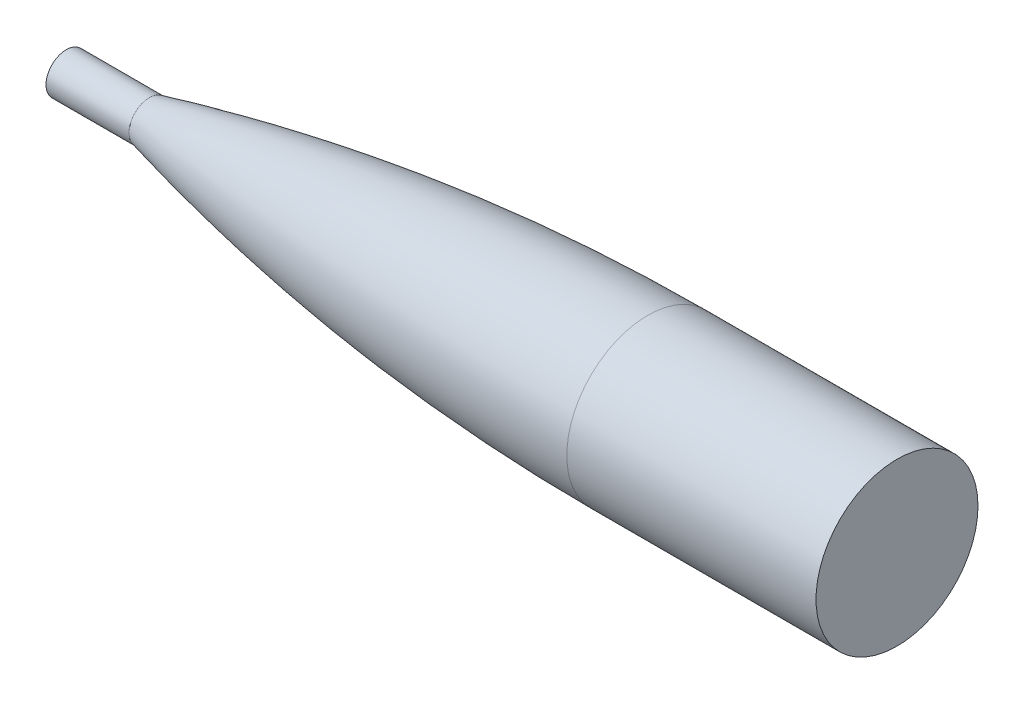
from build123d import *

# Parameters (mm, degrees)
SKETCH2_R           = 49.53
BOSS_EXTRUDE1_DEPTH = 152.4
SKETCH3_R           = 12.411567775
BOSS_EXTRUDE2_DEPTH = 50.8


with BuildPart() as part:
    # Sketch1 → Revolve2 (revolve)
    with BuildSketch(Plane(origin=(0, 0, 0), x_dir=(1, 0, 0), z_dir=(0, 1, 0))):
        with BuildLine():
            Line((355.600000053, 50.799999973), (355.600000053, 1.269999973))
            Line((355.600000053, 1.269999973), (50.800000047, 1.269999973))
            Line((50.800000047, 1.269999973), (50.800000047, 13.68156774))
            add(Edge.make_bspline(
                [(50.800000047, 13.68156774), (51.224607869, 13.786541703), (52.079748124, 13.99736018), (53.901316113, 14.445024847), (55.90428978, 14.933081433), (57.918204029, 15.420277853), (59.969167456, 15.913068852), (62.005618607, 16.398707152), (64.04585603, 16.881716673), (66.619566178, 17.486536085), (69.727395203, 18.209576077), (73.370678613, 19.04644661), (77.55044141, 19.991710093), (82.779136229, 21.155661521), (97.433989811, 24.348822924), (119.485629173, 28.81699746), (168.00075752, 37.516041455), (219.035004801, 44.081341124), (262.822405655, 47.820230422), (299.206459448, 49.570692635), (308.841173655, 49.947366018), (315.265578413, 50.162354186), (319.548981494, 50.29122703), (323.832782669, 50.405645805), (328.116966628, 50.505609209), (332.401425999, 50.591116104), (336.139078075, 50.653092889), (339.329601827, 50.697064227), (341.973247658, 50.727612371), (344.069774299, 50.748376802), (346.163273231, 50.76568058), (348.272494467, 50.77952366), (350.344714481, 50.789906003), (352.405704949, 50.79682758), (354.282013928, 50.799423175), (355.162608625, 50.799999974), (355.600000053, 50.799999973)],
                knots=[0.08282658, 0.08282658, 0.08282658, 0.08282658, 0.08282658, 0.088510594, 0.094194608, 0.099878623, 0.105562637, 0.111246651, 0.116930666, 0.12261468, 0.128298694, 0.139917182, 0.15153567, 0.163154157, 0.174772645, 0.198009616, 0.314194483, 0.407142375, 0.709223026, 0.755696971, 0.790552431, 0.802170918, 0.813789405, 0.825407891, 0.837026378, 0.848644864, 0.860263351, 0.871881838, 0.877565852, 0.883249866, 0.88893388, 0.894617894, 0.900301908, 0.905985922, 0.911669936, 0.91735395, 0.91735395, 0.91735395, 0.91735395, 0.91735395], degree=4))
        make_face()
    revolve(axis=Axis((355.600000053, 0, -1.269999973), (-1, 0, 0)))

    # Sketch2 → Boss-Extrude1 (add)
    with BuildSketch(Plane(origin=(355.600000053, 0, 0), x_dir=(0, 0, -1), z_dir=(1, 0, 0))):
        with Locations((1.269999973, 0)):
            Circle(SKETCH2_R)
    extrude(amount=BOSS_EXTRUDE1_DEPTH)

    # Sketch3 → Boss-Extrude2 (add)
    with BuildSketch(Plane.ZY.offset(-50.800000063)):
        with Locations((-1.269999973, 0)):
            Circle(SKETCH3_R)
    extrude(amount=BOSS_EXTRUDE2_DEPTH)


solid = part.part
